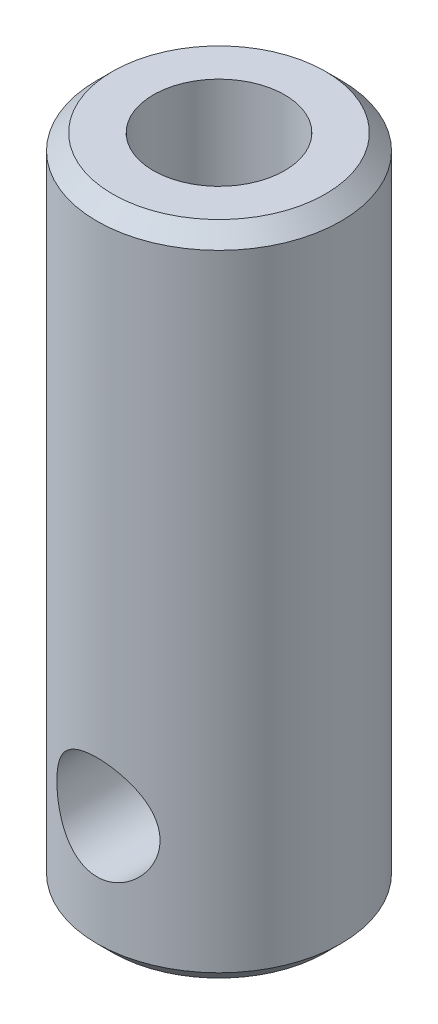
from build123d import *

# Parameters (mm, degrees)
SKETCH_1_R             = 3.9
EXTRUDE_1_DEPTH        = 21
HOLE_WIZARD_M4_1_D     = 3.3
HOLE_WIZARD_M5_1_D     = 4.2
HOLE_WIZARD_M5_1_DEPTH = 12
HOLE_WIZARD_M5_1_TIP   = 1.2618073
CHAMFER_1_SIZE         = 0.5


with BuildPart() as part:
    # 草图1 → 凸台-拉伸1 (new body)
    with BuildSketch(Plane(origin=(0, 0, 0), x_dir=(1, 0, 0), z_dir=(0, 1, 0))):
        Circle(SKETCH_1_R)
    extrude(amount=EXTRUDE_1_DEPTH)

    # M4 螺纹孔1 (through all)
    with Locations(Plane.XY.offset(3.9)):
        with Locations((0, 4)):
            Hole(HOLE_WIZARD_M4_1_D / 2)

    # M5 螺纹孔1
    with Locations(Plane(origin=(0, 21, 0), x_dir=(1, 0, 0), z_dir=(0, 1, 0))):
        with Locations((0, 0)):
            Hole(HOLE_WIZARD_M5_1_D / 2, depth=HOLE_WIZARD_M5_1_DEPTH)
            with Locations((0, 0, -(HOLE_WIZARD_M5_1_DEPTH + HOLE_WIZARD_M5_1_TIP / 2))):  # 118° drill point
                Cone(0, HOLE_WIZARD_M5_1_D / 2, HOLE_WIZARD_M5_1_TIP, mode=Mode.SUBTRACT)

    # 倒角1
    chamfer_1_edges = [part.edges().sort_by_distance(p)[0] for p in [
        (-3.9, 0, 0),
        (-3.9, 21, 0),
    ]]
    chamfer(chamfer_1_edges, length=CHAMFER_1_SIZE)


solid = part.part
